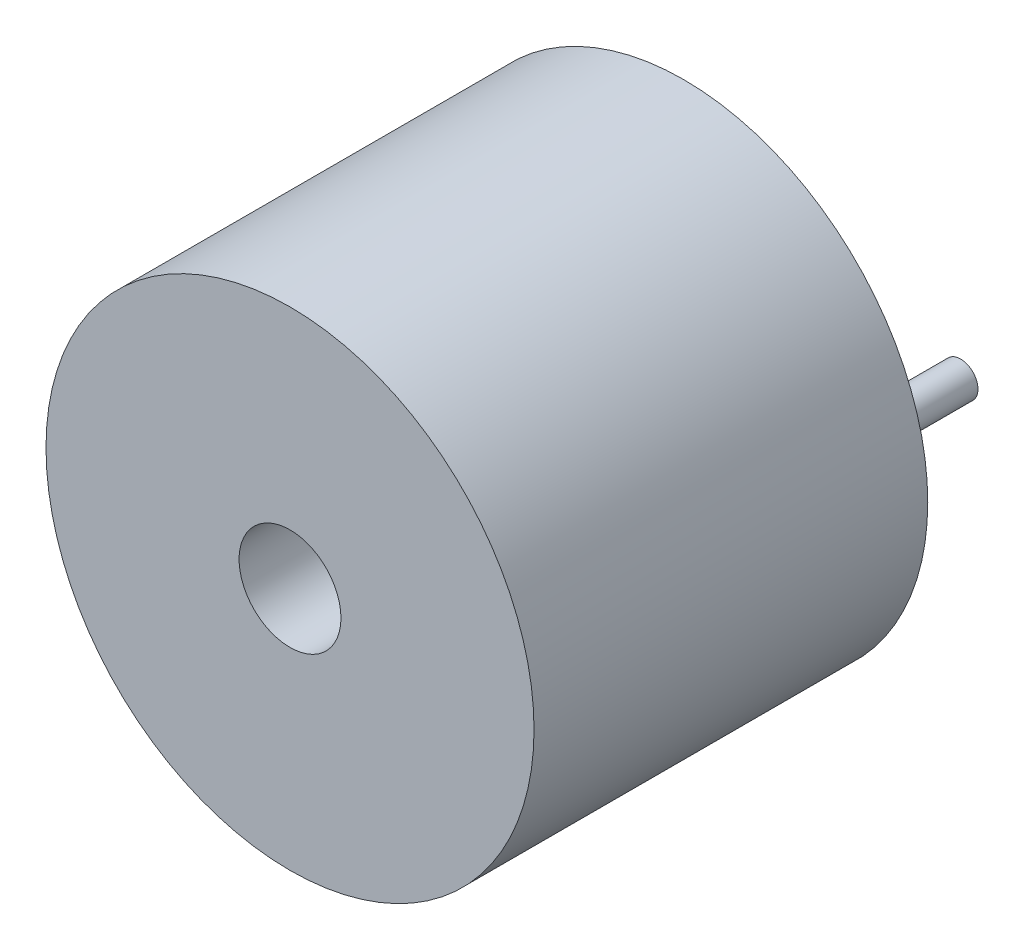
from build123d import *

# Parameters (mm, degrees)
SKETCH1_R           = 5.95
BOSS_EXTRUDE1_DEPTH = 9.6
SKETCH2_R           = 1.241958451
CUT_EXTRUDE1_DEPTH  = 2
SKETCH3_R           = 0.425
BOSS_EXTRUDE2_DEPTH = 3


with BuildPart() as part:
    # Sketch1 → Boss-Extrude1 (new body)
    with BuildSketch(Plane.XY):
        Circle(SKETCH1_R)
    extrude(amount=BOSS_EXTRUDE1_DEPTH)

    # Sketch2 → Cut-Extrude1 (cut)
    with BuildSketch(Plane.XY.offset(9.6)):
        Circle(SKETCH2_R)
    extrude(amount=-CUT_EXTRUDE1_DEPTH, mode=Mode.SUBTRACT)

    # Sketch3 → Boss-Extrude2 (add)
    with BuildSketch(Plane(origin=(0, 0, 0), x_dir=(-1, 0, 0), z_dir=(0, 0, -1))):
        with Locations((-3.75, 0)):
            Circle(SKETCH3_R)
        with Locations((3.75, 0)):
            Circle(SKETCH3_R)
    extrude(amount=BOSS_EXTRUDE2_DEPTH)


solid = part.part
